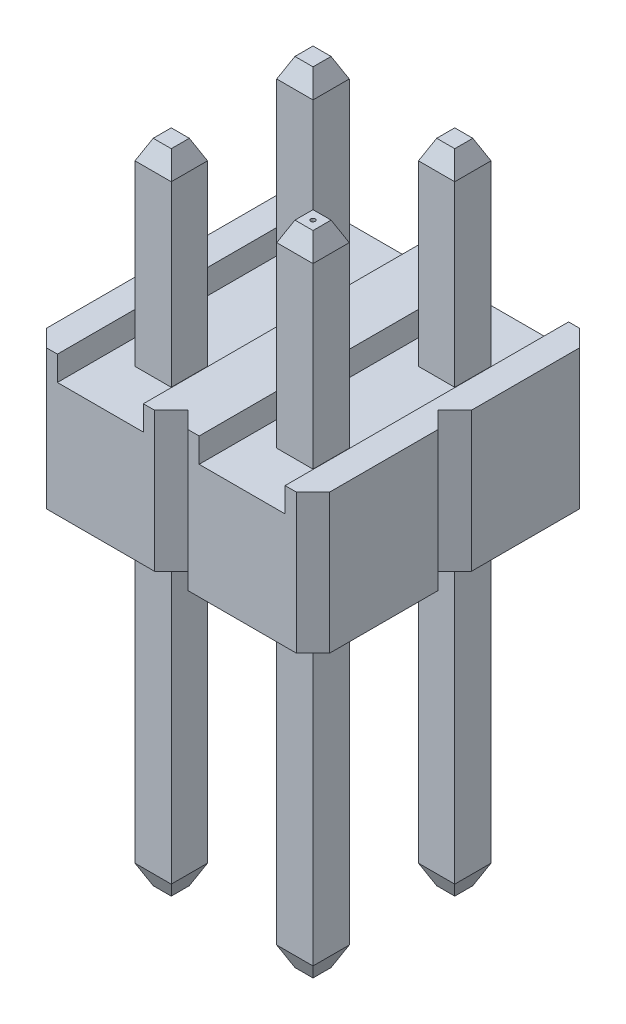
from build123d import *

# Parameters (mm, degrees)
EXTRUDE1_DEPTH                     = 2.5
SKETCH2_W                          = 1.54
SKETCH2_H                          = 0.508742985
CUT_EXTRUDE1_DEPTH                 = 12.5
SKETCH3_W                          = 0.65
SKETCH3_H                          = 0.65
EXTRUDE2_DEPTH                     = 3.54
CHAMFER1_SIZE                      = 0.35
CHAMFER1_SIZE2                     = 0.16320768
CHAMFER1_PART_2_SIZE               = 0.35
CHAMFER1_PART_2_SIZE2              = 0.16320768
CHAMFER1_PART_3_SIZE               = 0.35
CHAMFER1_PART_3_SIZE2              = 0.16320768
CHAMFER1_PART_4_SIZE               = 0.35
CHAMFER1_PART_4_SIZE2              = 0.16320768
SKETCH4_W                          = 0.65
SKETCH4_H                          = 0.65
EXTRUDE3_DEPTH                     = 6
CHAMFER2_SIZE                      = 0.35
CHAMFER2_SIZE2                     = 0.16320768
CHAMFER2_PART_2_SIZE               = 0.35
CHAMFER2_PART_2_SIZE2              = 0.16320768
CHAMFER2_PART_3_SIZE               = 0.35
CHAMFER2_PART_3_SIZE2              = 0.16320768
CHAMFER2_PART_4_SIZE               = 0.35
CHAMFER2_PART_4_SIZE2              = 0.16320768
LPATTERN3_COUNT                    = 2
LPATTERN3_PITCH                    = 2.54
LPATTERN3_COUNT_DIR2               = 2
LPATTERN3_PITCH_DIR2               = 2.54
LPATTERN4_COUNT                    = 2
LPATTERN4_PITCH                    = 2.54
LPATTERN4_COUNT_DIR2               = 2
LPATTERN4_PITCH_DIR2               = 2.54
CHAMFER1_OF_LPATTERN4_SIZE2        = 0.16320768
CHAMFER1_OF_LPATTERN4_SIZE         = 0.35
CHAMFER1_PART_2_OF_LPATTERN4_SIZE2 = 0.16320768
CHAMFER1_PART_2_OF_LPATTERN4_SIZE  = 0.35
CHAMFER1_PART_3_OF_LPATTERN4_SIZE2 = 0.16320768
CHAMFER1_PART_3_OF_LPATTERN4_SIZE  = 0.35
CHAMFER1_PART_4_OF_LPATTERN4_SIZE2 = 0.16320768
CHAMFER1_PART_4_OF_LPATTERN4_SIZE  = 0.35
CHAMFER2_OF_LPATTERN4_SIZE2        = 0.16320768
CHAMFER2_OF_LPATTERN4_SIZE         = 0.35
CHAMFER2_PART_2_OF_LPATTERN4_SIZE2 = 0.16320768
CHAMFER2_PART_2_OF_LPATTERN4_SIZE  = 0.35
CHAMFER2_PART_3_OF_LPATTERN4_SIZE2 = 0.16320768
CHAMFER2_PART_3_OF_LPATTERN4_SIZE  = 0.35
CHAMFER2_PART_4_OF_LPATTERN4_SIZE2 = 0.16320768
CHAMFER2_PART_4_OF_LPATTERN4_SIZE  = 0.35
ESBO_O1_R                          = 0.039608668
CORTE_EXTRUS_O1_DEPTH              = 0.1


with BuildPart() as part:
    # Sketch1 → Extrude1 (new body)
    with BuildSketch(Plane(origin=(0, 0, 0), x_dir=(1, 0, 0), z_dir=(0, 1, 0))):
        Polygon((-0.97, 1.27), (0.97, 1.27), (1.27, 0.97), (1.27, -0.97), (0.97, -1.27), (-0.97, -1.27), (-1.27, -0.97), (-1.27, 0.97), align=None)
    extrude1 = extrude(amount=EXTRUDE1_DEPTH)

    # Sketch2 → Cut-Extrude1 (cut)
    with BuildSketch(Plane.XY.offset(1.27)):
        with Locations((0, 2.314371493)):
            Rectangle(SKETCH2_W, SKETCH2_H)
    cut_extrude1 = extrude(amount=-CUT_EXTRUDE1_DEPTH, mode=Mode.SUBTRACT)

    # Sketch3 → Extrude2 (add)
    with BuildSketch(Plane(origin=(0, 2.06, 0), x_dir=(-1, 0, 0), z_dir=(0, 1, 0))):
        Rectangle(SKETCH3_W, SKETCH3_H)
    extrude2 = extrude(amount=EXTRUDE2_DEPTH)

    # Chamfer1
    chamfer1_edges = [part.edges().sort_by_distance(p)[0] for p in [
        (-0.325, 5.6, 0),
    ]]
    chamfer1_side = [part.faces().sort_by_distance(p)[0] for p in [
        (-0.325, 3.83, 0),
    ]]
    chamfer(chamfer1_edges, length=CHAMFER1_SIZE, length2=CHAMFER1_SIZE2, reference=chamfer1_side[0])

    # Chamfer1 part 2
    chamfer1_part_2_edges = [part.edges().sort_by_distance(p)[0] for p in [
        (0, 5.6, 0.325),
    ]]
    chamfer1_part_2_side = [part.faces().sort_by_distance(p)[0] for p in [
        (0, 3.83, 0.325),
    ]]
    chamfer(chamfer1_part_2_edges, length=CHAMFER1_PART_2_SIZE, length2=CHAMFER1_PART_2_SIZE2, reference=chamfer1_part_2_side[0])

    # Chamfer1 part 3
    chamfer1_part_3_edges = [part.edges().sort_by_distance(p)[0] for p in [
        (0.325, 5.6, 0),
    ]]
    chamfer1_part_3_side = [part.faces().sort_by_distance(p)[0] for p in [
        (0.325, 3.83, 0),
    ]]
    chamfer(chamfer1_part_3_edges, length=CHAMFER1_PART_3_SIZE, length2=CHAMFER1_PART_3_SIZE2, reference=chamfer1_part_3_side[0])

    # Chamfer1 part 4
    chamfer1_part_4_edges = [part.edges().sort_by_distance(p)[0] for p in [
        (0, 5.6, -0.325),
    ]]
    chamfer1_part_4_side = [part.faces().sort_by_distance(p)[0] for p in [
        (0, 3.83, -0.325),
    ]]
    chamfer(chamfer1_part_4_edges, length=CHAMFER1_PART_4_SIZE, length2=CHAMFER1_PART_4_SIZE2, reference=chamfer1_part_4_side[0])

    # Sketch4 → Extrude3 (add)
    with BuildSketch(Plane.XZ):
        Rectangle(SKETCH4_W, SKETCH4_H)
    extrude3 = extrude(amount=EXTRUDE3_DEPTH)

    # Chamfer2
    chamfer2_edges = [part.edges().sort_by_distance(p)[0] for p in [
        (-0.325, -6, 0),
    ]]
    chamfer2_side = [part.faces().sort_by_distance(p)[0] for p in [
        (-0.325, -3, 0),
    ]]
    chamfer(chamfer2_edges, length=CHAMFER2_SIZE, length2=CHAMFER2_SIZE2, reference=chamfer2_side[0])

    # Chamfer2 part 2
    chamfer2_part_2_edges = [part.edges().sort_by_distance(p)[0] for p in [
        (0, -6, -0.325),
    ]]
    chamfer2_part_2_side = [part.faces().sort_by_distance(p)[0] for p in [
        (0, -3, -0.325),
    ]]
    chamfer(chamfer2_part_2_edges, length=CHAMFER2_PART_2_SIZE, length2=CHAMFER2_PART_2_SIZE2, reference=chamfer2_part_2_side[0])

    # Chamfer2 part 3
    chamfer2_part_3_edges = [part.edges().sort_by_distance(p)[0] for p in [
        (0.325, -6, 0),
    ]]
    chamfer2_part_3_side = [part.faces().sort_by_distance(p)[0] for p in [
        (0.325, -3, 0),
    ]]
    chamfer(chamfer2_part_3_edges, length=CHAMFER2_PART_3_SIZE, length2=CHAMFER2_PART_3_SIZE2, reference=chamfer2_part_3_side[0])

    # Chamfer2 part 4
    chamfer2_part_4_edges = [part.edges().sort_by_distance(p)[0] for p in [
        (0, -6, 0.325),
    ]]
    chamfer2_part_4_side = [part.faces().sort_by_distance(p)[0] for p in [
        (0, -3, 0.325),
    ]]
    chamfer(chamfer2_part_4_edges, length=CHAMFER2_PART_4_SIZE, length2=CHAMFER2_PART_4_SIZE2, reference=chamfer2_part_4_side[0])

    # LPattern3: Extrude1, Cut-Extrude1 2 × 2
    with Locations(*[(-j * LPATTERN3_PITCH_DIR2, 0, -i * LPATTERN3_PITCH) for i in range(LPATTERN3_COUNT) for j in range(LPATTERN3_COUNT_DIR2) if (i, j) != (0, 0)]):
        add(extrude1)
        add(cut_extrude1, mode=Mode.SUBTRACT)

    # LPattern4: Extrude2, Extrude3 2 × 2
    with Locations(*[(-j * LPATTERN4_PITCH_DIR2, 0, -i * LPATTERN4_PITCH) for i in range(LPATTERN4_COUNT) for j in range(LPATTERN4_COUNT_DIR2) if (i, j) != (0, 0)]):
        add(extrude2)
        add(extrude3)

    # Chamfer1 of LPattern4
    chamfer1_of_lpattern4_edges = [part.edges().sort_by_distance(p)[0] for p in [
        (-2.865, 5.6, 0),
        (-0.325, 5.6, -2.54),
        (-2.865, 5.6, -2.54),
    ]]
    chamfer(chamfer1_of_lpattern4_edges, length=CHAMFER1_OF_LPATTERN4_SIZE, length2=CHAMFER1_OF_LPATTERN4_SIZE2)

    # Chamfer1 part 2 of LPattern4
    chamfer1_part_2_of_lpattern4_edges = [part.edges().sort_by_distance(p)[0] for p in [
        (-2.54, 5.6, 0.325),
        (0, 5.6, -2.215),
        (-2.54, 5.6, -2.215),
    ]]
    chamfer(chamfer1_part_2_of_lpattern4_edges, length=CHAMFER1_PART_2_OF_LPATTERN4_SIZE, length2=CHAMFER1_PART_2_OF_LPATTERN4_SIZE2)

    # Chamfer1 part 3 of LPattern4
    chamfer1_part_3_of_lpattern4_edges = [part.edges().sort_by_distance(p)[0] for p in [
        (-2.215, 5.6, 0),
        (0.325, 5.6, -2.54),
        (-2.215, 5.6, -2.54),
    ]]
    chamfer(chamfer1_part_3_of_lpattern4_edges, length=CHAMFER1_PART_3_OF_LPATTERN4_SIZE, length2=CHAMFER1_PART_3_OF_LPATTERN4_SIZE2)

    # Chamfer1 part 4 of LPattern4
    chamfer1_part_4_of_lpattern4_edges = [part.edges().sort_by_distance(p)[0] for p in [
        (-2.54, 5.6, -0.325),
        (0, 5.6, -2.865),
        (-2.54, 5.6, -2.865),
    ]]
    chamfer(chamfer1_part_4_of_lpattern4_edges, length=CHAMFER1_PART_4_OF_LPATTERN4_SIZE, length2=CHAMFER1_PART_4_OF_LPATTERN4_SIZE2)

    # Chamfer2 of LPattern4
    chamfer2_of_lpattern4_edges = [part.edges().sort_by_distance(p)[0] for p in [
        (-2.865, -6, 0),
        (-0.325, -6, -2.54),
        (-2.865, -6, -2.54),
    ]]
    chamfer(chamfer2_of_lpattern4_edges, length=CHAMFER2_OF_LPATTERN4_SIZE, length2=CHAMFER2_OF_LPATTERN4_SIZE2)

    # Chamfer2 part 2 of LPattern4
    chamfer2_part_2_of_lpattern4_edges = [part.edges().sort_by_distance(p)[0] for p in [
        (-2.54, -6, -0.325),
        (0, -6, -2.865),
        (-2.54, -6, -2.865),
    ]]
    chamfer(chamfer2_part_2_of_lpattern4_edges, length=CHAMFER2_PART_2_OF_LPATTERN4_SIZE, length2=CHAMFER2_PART_2_OF_LPATTERN4_SIZE2)

    # Chamfer2 part 3 of LPattern4
    chamfer2_part_3_of_lpattern4_edges = [part.edges().sort_by_distance(p)[0] for p in [
        (-2.215, -6, 0),
        (0.325, -6, -2.54),
        (-2.215, -6, -2.54),
    ]]
    chamfer(chamfer2_part_3_of_lpattern4_edges, length=CHAMFER2_PART_3_OF_LPATTERN4_SIZE, length2=CHAMFER2_PART_3_OF_LPATTERN4_SIZE2)

    # Chamfer2 part 4 of LPattern4
    chamfer2_part_4_of_lpattern4_edges = [part.edges().sort_by_distance(p)[0] for p in [
        (-2.54, -6, 0.325),
        (0, -6, -2.215),
        (-2.54, -6, -2.215),
    ]]
    chamfer(chamfer2_part_4_of_lpattern4_edges, length=CHAMFER2_PART_4_OF_LPATTERN4_SIZE, length2=CHAMFER2_PART_4_OF_LPATTERN4_SIZE2)

    # Esboço1 → Corte-extrusão1 (cut)
    with BuildSketch(Plane(origin=(0, 5.6, 0), x_dir=(1, 0, 0), z_dir=(0, 1, 0))):
        Circle(ESBO_O1_R)
    extrude(amount=-CORTE_EXTRUS_O1_DEPTH, mode=Mode.SUBTRACT)


solid = part.part
